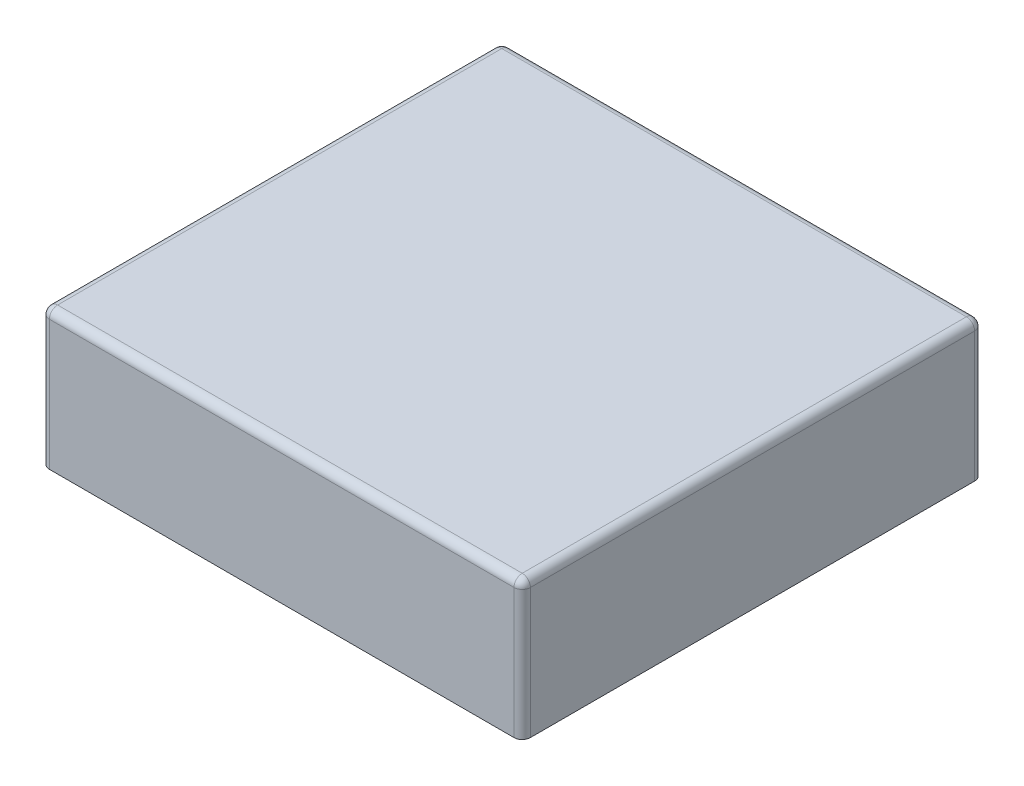
from build123d import *

# Parameters (mm, degrees)
SKETCH_1_W      = 117.11
SKETCH_1_H      = 112.14
EXTRUDE_1_DEPTH = 33.65
SKETCH_2_R      = 5
EXTRUDE_2_DEPTH = 3
FILLET_1_R      = 2


with BuildPart() as part:
    # 草图1 → 凸台-拉伸1 (new body)
    with BuildSketch(Plane(origin=(0, 0, 0), x_dir=(1, 0, 0), z_dir=(0, 1, 0))):
        Rectangle(SKETCH_1_W, SKETCH_1_H)
    extrude(amount=EXTRUDE_1_DEPTH)

    # 草图2 → 凸台-拉伸2 (add)
    with BuildSketch(Plane.XZ):
        with Locations((-47, 46)):
            Circle(SKETCH_2_R)
        with Locations((47, 46)):
            Circle(SKETCH_2_R)
        with Locations((47, -46)):
            Circle(SKETCH_2_R)
        with Locations((-47, -46)):
            Circle(SKETCH_2_R)
    extrude(amount=EXTRUDE_2_DEPTH)

    # 圆角1
    fillet_1_edges = [part.edges().sort_by_distance(p)[0] for p in [
        (-58.555, 33.65, 0),
        (0, 33.65, 56.07),
        (58.555, 33.65, 0),
        (58.555, 16.825, 56.07),
        (-58.555, 16.825, 56.07),
        (-58.555, 16.825, -56.07),
        (58.555, 16.825, -56.07),
        (0, 33.65, -56.07),
    ]]
    fillet(fillet_1_edges, radius=FILLET_1_R)


solid = part.part
